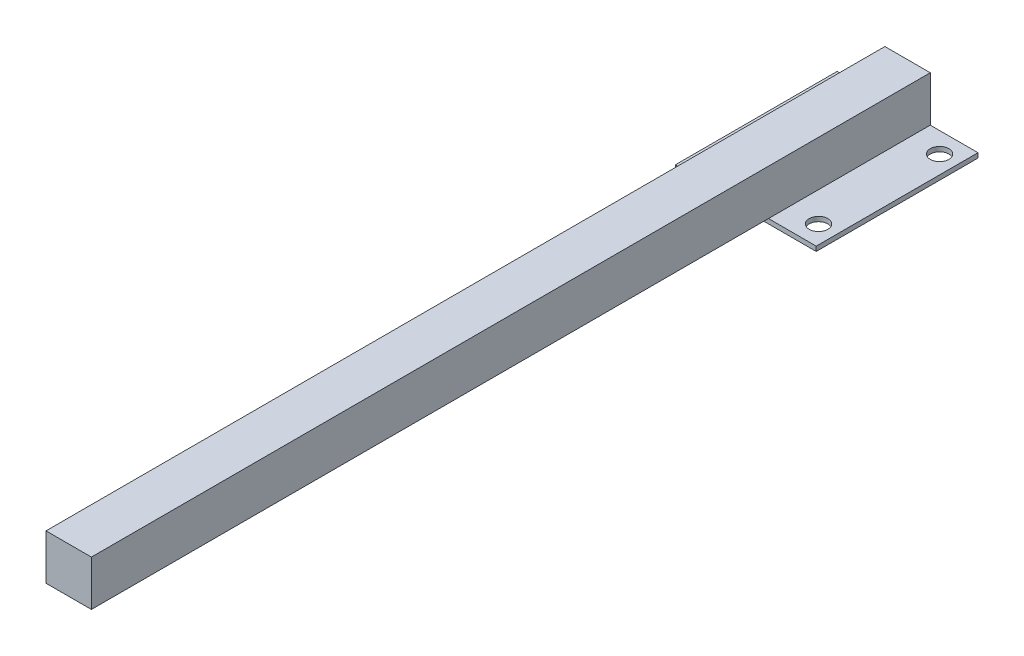
from build123d import *

# Parameters (mm, degrees)
SKETCH1_W                = 60.5
SKETCH1_H                = 69.5
SKETCH1_R                = 4
BOSS_EXTRUDE1_DEPTH      = 2
SKETCH2_W                = 19.5
SKETCH2_H                = 19.5
BOSS_EXTRUDE2_DEPTH      = 325.596
BOSS_EXTRUDE2_DEPTH_BACK = 34.75


with BuildPart() as part:
    # Sketch1 → Boss-Extrude1 (new body)
    with BuildSketch(Plane(origin=(0, 0, 0), x_dir=(1, 0, 0), z_dir=(0, 1, 0))):
        Rectangle(SKETCH1_W, SKETCH1_H)
        with Locations((-22.5, 26)):
            Circle(SKETCH1_R, mode=Mode.SUBTRACT)
        with Locations((22.5, 26)):
            Circle(SKETCH1_R, mode=Mode.SUBTRACT)
        with Locations((-22.5, -26)):
            Circle(SKETCH1_R, mode=Mode.SUBTRACT)
        with Locations((22.5, -26)):
            Circle(SKETCH1_R, mode=Mode.SUBTRACT)
    extrude(amount=BOSS_EXTRUDE1_DEPTH)

    # Sketch2 → Boss-Extrude2 (add, two sides)
    with BuildSketch(Plane.XY) as boss_extrude2_sk:
        with Locations((0, 11.75)):
            Rectangle(SKETCH2_W, SKETCH2_H)
    extrude(amount=BOSS_EXTRUDE2_DEPTH)
    extrude(boss_extrude2_sk.sketch, amount=-BOSS_EXTRUDE2_DEPTH_BACK)


solid = part.part
